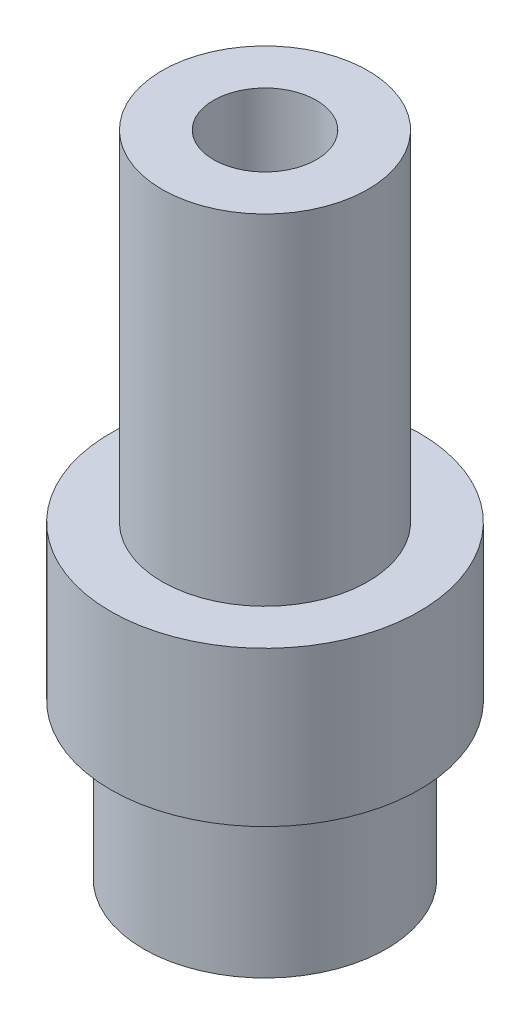
from build123d import *


with BuildPart() as part:
    # Sketch1 → Revolve1 (revolve)
    with BuildSketch(Plane.XY):
        Polygon((-3.175, 0), (-6.35, 0), (-6.35, -20.955), (-9.525, -20.955), (-9.525, -30.48), (-7.493, -30.48), (-7.493, -40.005), (-5.207, -40.005), (-5.207, -27.305), (-3.175, -27.305), align=None)
    revolve(axis=Axis((0, 0, 0), (0, -1, 0)))


solid = part.part
